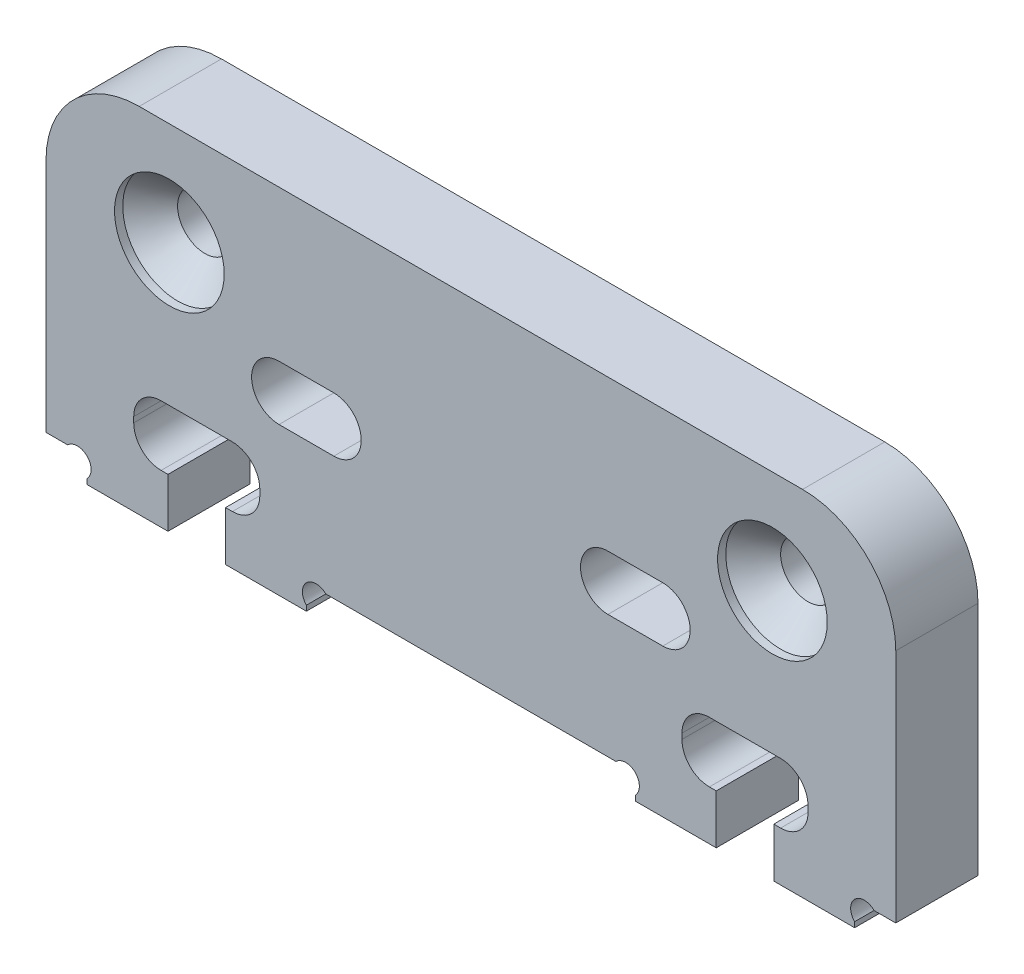
from build123d import *

# Parameters (mm, degrees)
BASE_SHAPE_DEPTH                               = 3
EDGE_RADIUSES_R                                = 3.4
CAMERA_MOUNT_HOLES_REACH                       = 5
SKETCH3_R                                      = 1
CSK_FOR_M2_FLAT_HEAD_MACHINE_SCREW1_AT_2_COUNT = 2
CSK_FOR_M2_FLAT_HEAD_MACHINE_SCREW1_AT_2_PITCH = 22
MILLING_RADIUSES_R                             = 1
SKETCH8_R                                      = 0.5
MILLING_CUTS_1MM_DEPTH                         = 3


with BuildPart() as part:
    # Sketch1 → Base shape (new body)
    with BuildSketch(Plane.XY):
        Polygon((15.5, 6), (-15.5, 6), (-15.5, -6), (-14, -6), (-14, -6.9), (-11.05, -6.9), (-11.05, -5.1), (-12.3, -5.1), (-12.3, -2.9), (-7.7, -2.9), (-7.7, -5.1), (-8.95, -5.1), (-8.95, -6.9), (-6, -6.9), (-6, -6), (6, -6), (6, -6.9), (8.95, -6.9), (8.95, -5.1), (7.7, -5.1), (7.7, -2.9), (12.3, -2.9), (12.3, -5.1), (11.05, -5.1), (11.05, -6.9), (14, -6.9), (14, -6), (15.5, -6), align=None)
        with BuildLine():
            Line((-5, -1.5), (-7, -1.5))
            ThreePointArc((-7, -1.5), (-8, -0.5), (-7, 0.5))
            Line((-7, 0.5), (-5, 0.5))
            ThreePointArc((-5, 0.5), (-4, -0.5), (-5, -1.5))
        make_face(mode=Mode.SUBTRACT)
        with BuildLine():
            ThreePointArc((7, 0.5), (8, -0.5), (7, -1.5))
            Line((7, -1.5), (5, -1.5))
            ThreePointArc((5, -1.5), (4, -0.5), (5, 0.5))
            Line((5, 0.5), (7, 0.5))
        make_face(mode=Mode.SUBTRACT)
    extrude(amount=BASE_SHAPE_DEPTH)

    # Edge radiuses
    edge_radiuses_edges = [part.edges().sort_by_distance(p)[0] for p in [
        (-15.5, 6, 1.5),
        (15.5, 6, 1.5),
    ]]
    fillet(edge_radiuses_edges, radius=EDGE_RADIUSES_R)

    # Sketch3 → Camera mount holes (cut, up to next)
    with BuildSketch(Plane(origin=(0, 0, 3), x_dir=(-1, 0, 0), z_dir=(0, 0, -1)), mode=Mode.PRIVATE) as camera_mount_holes_sk1:
        with Locations((-11, 2.25)):
            Circle(SKETCH3_R)
    camera_mount_holes_tool1 = extrude(camera_mount_holes_sk1.sketch, amount=CAMERA_MOUNT_HOLES_REACH, mode=Mode.PRIVATE) & part.part
    add(camera_mount_holes_tool1.solids().sort_by_distance((11, 2.25, 3))[0], mode=Mode.SUBTRACT)
    # Sketch3 → Camera mount holes (cut, up to next)
    with BuildSketch(Plane(origin=(0, 0, 3), x_dir=(-1, 0, 0), z_dir=(0, 0, -1)), mode=Mode.PRIVATE) as camera_mount_holes_sk2:
        with Locations((11, 2.25)):
            Circle(SKETCH3_R)
    camera_mount_holes_tool2 = extrude(camera_mount_holes_sk2.sketch, amount=CAMERA_MOUNT_HOLES_REACH, mode=Mode.PRIVATE) & part.part
    add(camera_mount_holes_tool2.solids().sort_by_distance((-11, 2.25, 3))[0], mode=Mode.SUBTRACT)

    # Sketch5 → CSK for M2 Flat Head Machine Screw1 (revolve, cut)
    with BuildSketch(Plane(origin=(-11, 2.25, 3), x_dir=(0, -1, 0), z_dir=(1, 0, 0))):
        Polygon((0, 0), (0, 3), (1, 3), (1, 1.3), (2, 0.3), (2, 0), align=None)
    csk_for_m2_flat_head_machine_screw1 = revolve(axis=Axis((-11, 2.25, 9.35), (0, 0, -1)), mode=Mode.SUBTRACT)

    # CSK for M2 Flat Head Machine Screw1 at 2: CSK for M2 Flat Head Machine Screw1 ×2
    with Locations(*[(i * CSK_FOR_M2_FLAT_HEAD_MACHINE_SCREW1_AT_2_PITCH, 0, 0) for i in range(1, CSK_FOR_M2_FLAT_HEAD_MACHINE_SCREW1_AT_2_COUNT)]):
        add(csk_for_m2_flat_head_machine_screw1, mode=Mode.SUBTRACT)

    # Milling radiuses
    milling_radiuses_edges = [part.edges().sort_by_distance(p)[0] for p in [
        (-7.7, -5.1, 1.5),
        (-7.7, -2.9, 1.5),
        (-12.3, -2.9, 1.5),
        (-12.3, -5.1, 1.5),
        (12.3, -5.1, 1.5),
        (12.3, -2.9, 1.5),
        (7.7, -2.9, 1.5),
        (7.7, -5.1, 1.5),
    ]]
    fillet(milling_radiuses_edges, radius=MILLING_RADIUSES_R)

    # Sketch8 → Milling cuts 1mm (cut)
    with BuildSketch(Plane(origin=(0, 0, 3), x_dir=(-1, 0, 0), z_dir=(0, 0, -1))):
        with Locations((-14.353553391, -6.353553391)):
            Circle(SKETCH8_R)
        with Locations((14.353553391, -6.353553391)):
            Circle(SKETCH8_R)
        with Locations((-5.646446609, -6.353553391)):
            Circle(SKETCH8_R)
        with Locations((5.646446609, -6.353553391)):
            Circle(SKETCH8_R)
    extrude(amount=MILLING_CUTS_1MM_DEPTH, mode=Mode.SUBTRACT)


solid = part.part
